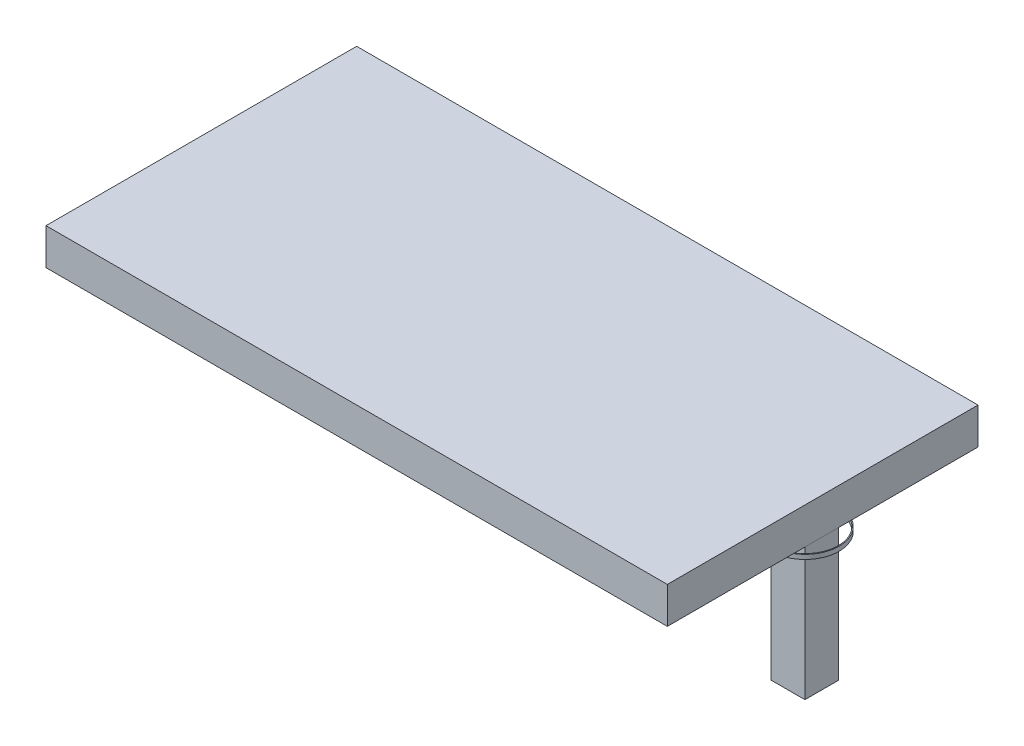
from build123d import *

# Parameters (mm, degrees)
SKETCH1_W           = 700
SKETCH1_H           = 350
SKETCH1_W_2         = 620
SKETCH1_H_2         = 270
BOSS_EXTRUDE1_DEPTH = 40
SKETCH2_W           = 700
SKETCH2_H           = 350
BOSS_EXTRUDE2_DEPTH = 1
SKETCH3_W           = 38
SKETCH3_H           = 38
BOSS_EXTRUDE3_DEPTH = 150
SKETCH4_W           = 19
SKETCH4_H           = 19
BOSS_EXTRUDE4_DEPTH = 20
SKETCH5_R           = 38.5
SKETCH5_R_2         = 37.5
BOSS_EXTRUDE5_DEPTH = 5


with BuildPart() as part:
    # Sketch1 → Boss-Extrude1 (new body)
    with BuildSketch(Plane(origin=(0, 0, 0), x_dir=(1, 0, 0), z_dir=(0, 1, 0))):
        Rectangle(SKETCH1_W, SKETCH1_H)
        Rectangle(SKETCH1_W_2, SKETCH1_H_2, mode=Mode.SUBTRACT)
    extrude(amount=BOSS_EXTRUDE1_DEPTH)

    # Sketch2 → Boss-Extrude2 (add)
    with BuildSketch(Plane(origin=(0, 40, 0), x_dir=(1, 0, 0), z_dir=(0, 1, 0))):
        Rectangle(SKETCH2_W, SKETCH2_H)
    extrude(amount=BOSS_EXTRUDE2_DEPTH)

    # Sketch3 → Boss-Extrude3 (add)
    with BuildSketch(Plane.XZ):
        with Locations((-330, 0)):
            Rectangle(SKETCH3_W, SKETCH3_H)
        with Locations((330, 0)):
            Rectangle(SKETCH3_W, SKETCH3_H)
    extrude(amount=BOSS_EXTRUDE3_DEPTH)

    # Sketch4 → Boss-Extrude4 (add)
    with BuildSketch(Plane.XZ):
        with Locations((-41.5, 144.5)):
            Rectangle(SKETCH4_W, SKETCH4_H)
    extrude(amount=BOSS_EXTRUDE4_DEPTH)

    # Sketch5 → Boss-Extrude5 (add)
    with BuildSketch(Plane.XZ):
        with Locations((-330, 0)):
            Circle(SKETCH5_R)
        with Locations((-330, 0)):
            Circle(SKETCH5_R_2, mode=Mode.SUBTRACT)
        with Locations((330, 0)):
            Circle(SKETCH5_R)
        with Locations((330, 0)):
            Circle(SKETCH5_R_2, mode=Mode.SUBTRACT)
    extrude(amount=BOSS_EXTRUDE5_DEPTH)


solid = part.part
